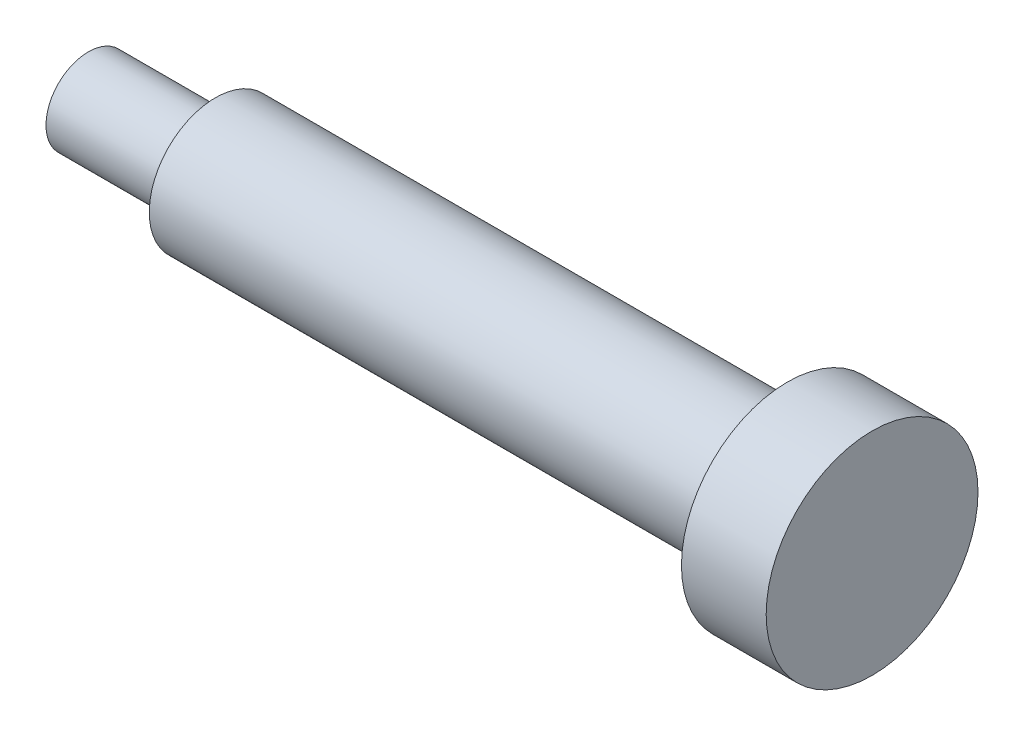
from build123d import *

# Parameters (mm, degrees)
SKETCH1_W = 6
SKETCH1_H = 2


with BuildPart() as part:
    # Sketch1 → Revolve1 (revolve)
    with BuildSketch(Plane.XY, mode=Mode.PRIVATE) as revolve1_sk:
        Polygon((-12.5, 2), (-12.5, 0), (14.5, 0), (14.5, 3.125), (-12.5, 3.125), align=None)
        with Locations((-15.5, 1)):
            Rectangle(SKETCH1_W, SKETCH1_H)
        Polygon((14.5, 3.125), (14.5, 0), (18.5, 0), (18.5, 5), (14.5, 5), align=None)
    revolve(revolve1_sk.sketch.rotate(Axis((-18.5, 0, 0), (1, 0, 0)), 180), axis=Axis((-18.5, 0, 0), (1, 0, 0)))


solid = part.part
